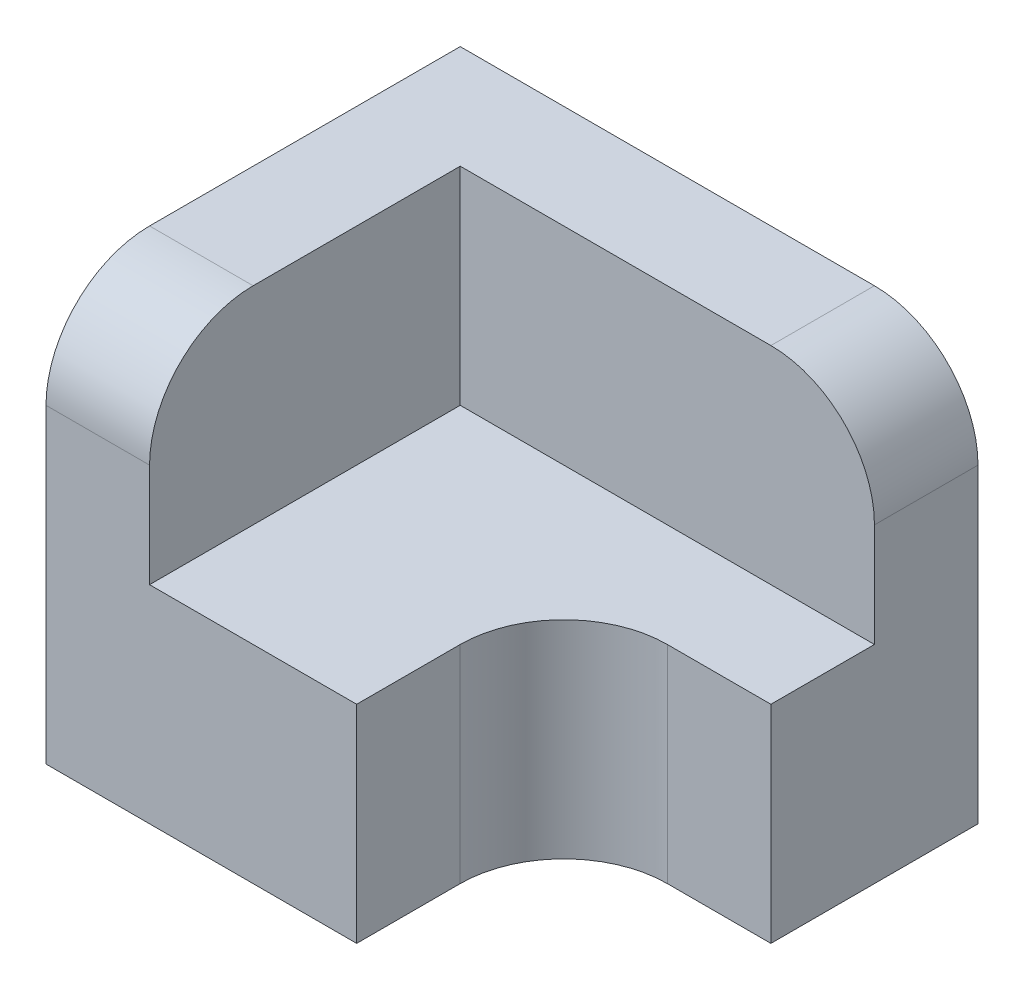
from build123d import *

# Parameters (mm, degrees)
EXTRUDE_1_DEPTH = 10
EXTRUDE_2_DEPTH = 20
FILLET_1_R      = 5


with BuildPart() as part:
    # 草圖1 → 填料-伸長1 (new body)
    with BuildSketch(Plane(origin=(0, 0, 0), x_dir=(1, 0, 0), z_dir=(0, 1, 0))):
        with BuildLine():
            Line((-12.5, -10), (2.5, -10))
            Line((2.5, -10), (2.5, -5))
            ThreePointArc((2.5, -5), (3.964466094, -1.464466094), (7.5, 0))
            Line((7.5, 0), (12.5, 0))
            Line((12.5, 0), (12.5, 10))
            Line((12.5, 10), (-12.5, 10))
            Line((-12.5, 10), (-12.5, -10))
        make_face()
    extrude(amount=EXTRUDE_1_DEPTH)

    # 草圖1<3> → 填料-伸長2 (add)
    with BuildSketch(Plane(origin=(0, 0, 0), x_dir=(1, 0, 0), z_dir=(0, 1, 0))):
        Polygon((-12.5, 5), (-12.5, -10), (-7.5, -10), (-7.5, 5), (12.5, 5), (12.5, 10), (-7.5, 10), (-12.5, 10), align=None)
    extrude(amount=EXTRUDE_2_DEPTH)

    # 圓角1
    fillet_1_edges = [part.edges().sort_by_distance(p)[0] for p in [
        (-10, 20, 10),
        (12.5, 20, -7.5),
    ]]
    fillet(fillet_1_edges, radius=FILLET_1_R)


solid = part.part
